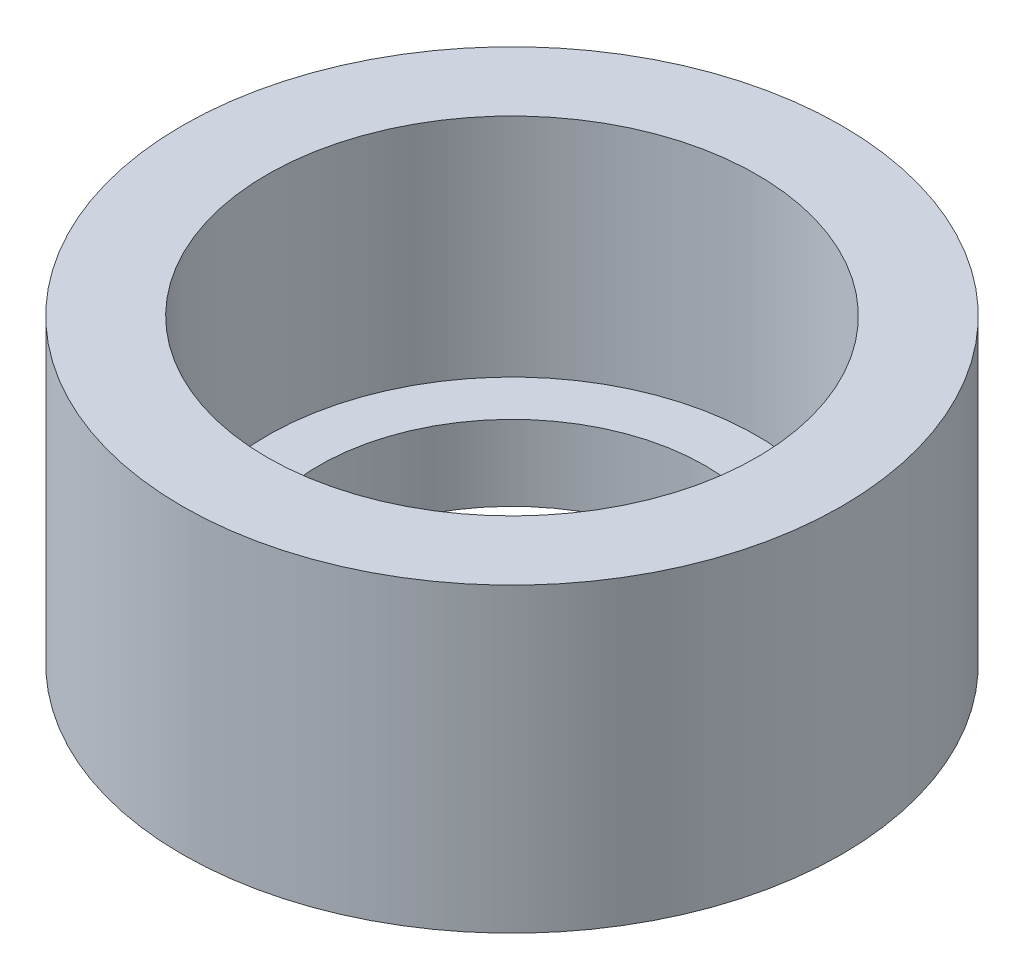
from build123d import *

# Parameters (mm, degrees)
SKETCH1_R           = 8.75
SKETCH1_R_2         = 5.125
BOSS_EXTRUDE1_DEPTH = 8
SKETCH2_R           = 6.5
CUT_EXTRUDE1_DEPTH  = 6


with BuildPart() as part:
    # Sketch1 → Boss-Extrude1 (new body)
    with BuildSketch(Plane(origin=(0, 0, 0), x_dir=(1, 0, 0), z_dir=(0, 1, 0))):
        Circle(SKETCH1_R)
        Circle(SKETCH1_R_2, mode=Mode.SUBTRACT)
    extrude(amount=BOSS_EXTRUDE1_DEPTH)

    # Sketch2 → Cut-Extrude1 (cut)
    with BuildSketch(Plane(origin=(0, 8, 0), x_dir=(1, 0, 0), z_dir=(0, 1, 0))):
        Circle(SKETCH2_R)
    extrude(amount=-CUT_EXTRUDE1_DEPTH, mode=Mode.SUBTRACT)


solid = part.part
